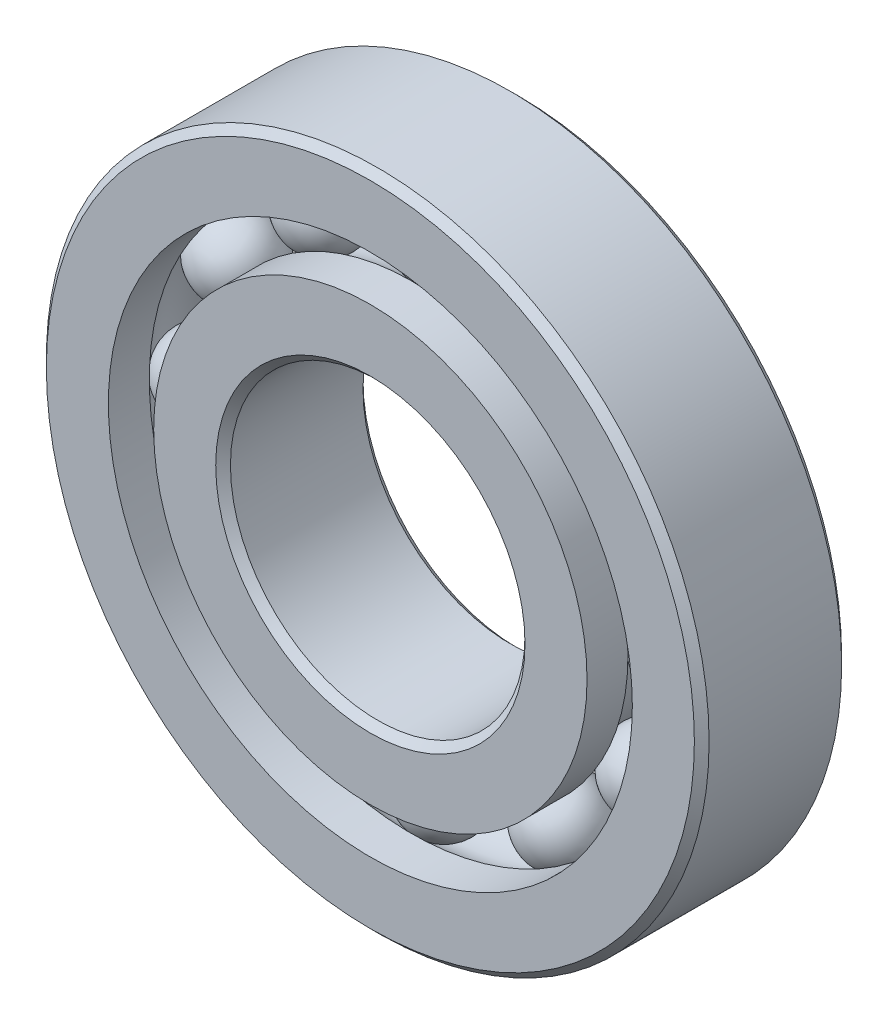
from build123d import *

# Parameters (mm, degrees)
CIRPATTERN1_COUNT = 12


with BuildPart() as part:
    # Sketch1 → Revolve1 (revolve)
    with BuildSketch(Plane(origin=(0, 0, 0), x_dir=(0, 0, -1), z_dir=(1, 0, 0))):
        with BuildLine():
            Line((2.8575, 14.2875), (-2.8575, 14.2875))
            Line((-2.8575, 14.2875), (-3.175, 13.97))
            Line((-3.175, 13.97), (-3.175, 11.295673077))
            Line((-3.175, 11.295673077), (-1.411111111, 11.295673077))
            ThreePointArc((-1.411111111, 11.295673077), (0, 12.035028901), (1.411111111, 11.295673077))
            Line((1.411111111, 11.295673077), (3.175, 11.295673077))
            Line((3.175, 11.295673077), (3.175, 13.97))
            Line((3.175, 13.97), (2.8575, 14.2875))
        make_face()
    revolve(axis=Axis((0, 0, 3.175), (0, 0, -1)))


with BuildPart() as body_2:
    # Sketch3 → Revolve3 (revolve)
    with BuildSketch(Plane(origin=(0, 0, 0), x_dir=(0, 0, -1), z_dir=(1, 0, 0))):
        with BuildLine():
            Line((-3.175, 9.341826923), (-1.411111111, 9.341826923))
            ThreePointArc((-1.411111111, 9.341826923), (0, 8.602471099), (1.411111111, 9.341826923))
            Line((1.411111111, 9.341826923), (3.175, 9.341826923))
            Line((3.175, 9.341826923), (3.175, 6.6675))
            Line((3.175, 6.6675), (2.8575, 6.35))
            Line((2.8575, 6.35), (-2.8575, 6.35))
            Line((-2.8575, 6.35), (-3.175, 6.6675))
            Line((-3.175, 6.6675), (-3.175, 9.341826923))
        make_face()
    revolve(axis=Axis((0, 0, 3.175), (0, 0, -1)))


with BuildPart() as body_3:
    # Sketch4 → Revolve4 (revolve)
    with BuildSketch(Plane(origin=(0, 0, 0), x_dir=(0, 0, -1), z_dir=(1, 0, 0))):
        with BuildLine():
            Line((-1.716278901, 10.31875), (1.716278901, 10.31875))
            ThreePointArc((1.716278901, 10.31875), (0, 12.035028901), (-1.716278901, 10.31875))
        make_face()
    revolve(axis=Axis((0, 10.31875, 1.716278901), (0, 0, -1)))


with BuildPart() as cirpattern1_1:
    # CirPattern1: pattern copy
    add(body_3.part.rotate(Axis((0, 0, -3.175), (0, 0, 1)), 1 * 360 / CIRPATTERN1_COUNT))


with BuildPart() as cirpattern1_2:
    # CirPattern1: pattern copy
    add(body_3.part.rotate(Axis((0, 0, -3.175), (0, 0, 1)), 2 * 360 / CIRPATTERN1_COUNT))


with BuildPart() as cirpattern1_3:
    # CirPattern1: pattern copy
    add(body_3.part.rotate(Axis((0, 0, -3.175), (0, 0, 1)), 3 * 360 / CIRPATTERN1_COUNT))


with BuildPart() as cirpattern1_4:
    # CirPattern1: pattern copy
    add(body_3.part.rotate(Axis((0, 0, -3.175), (0, 0, 1)), 4 * 360 / CIRPATTERN1_COUNT))


with BuildPart() as cirpattern1_5:
    # CirPattern1: pattern copy
    add(body_3.part.rotate(Axis((0, 0, -3.175), (0, 0, 1)), 5 * 360 / CIRPATTERN1_COUNT))


with BuildPart() as cirpattern1_6:
    # CirPattern1: pattern copy
    add(body_3.part.rotate(Axis((0, 0, -3.175), (0, 0, 1)), 6 * 360 / CIRPATTERN1_COUNT))


with BuildPart() as cirpattern1_7:
    # CirPattern1: pattern copy
    add(body_3.part.rotate(Axis((0, 0, -3.175), (0, 0, 1)), 7 * 360 / CIRPATTERN1_COUNT))


with BuildPart() as cirpattern1_8:
    # CirPattern1: pattern copy
    add(body_3.part.rotate(Axis((0, 0, -3.175), (0, 0, 1)), 8 * 360 / CIRPATTERN1_COUNT))


with BuildPart() as cirpattern1_9:
    # CirPattern1: pattern copy
    add(body_3.part.rotate(Axis((0, 0, -3.175), (0, 0, 1)), 9 * 360 / CIRPATTERN1_COUNT))


with BuildPart() as cirpattern1_10:
    # CirPattern1: pattern copy
    add(body_3.part.rotate(Axis((0, 0, -3.175), (0, 0, 1)), 10 * 360 / CIRPATTERN1_COUNT))


with BuildPart() as cirpattern1_11:
    # CirPattern1: pattern copy
    add(body_3.part.rotate(Axis((0, 0, -3.175), (0, 0, 1)), 11 * 360 / CIRPATTERN1_COUNT))


solid = Compound([part.part, body_2.part, body_3.part, cirpattern1_1.part, cirpattern1_2.part, cirpattern1_3.part, cirpattern1_4.part, cirpattern1_5.part, cirpattern1_6.part, cirpattern1_7.part, cirpattern1_8.part, cirpattern1_9.part, cirpattern1_10.part, cirpattern1_11.part])
